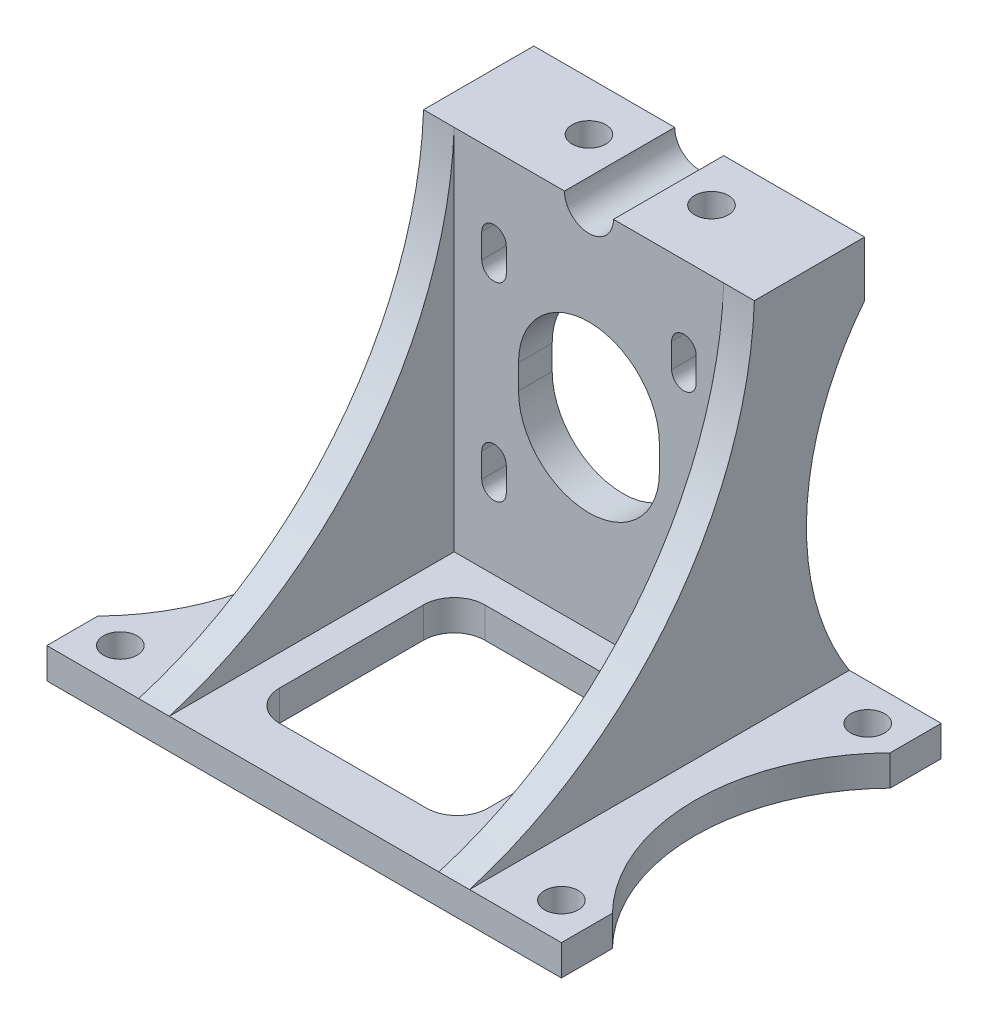
from build123d import *

# Parameters (mm, degrees)
BOSS_EXTRUDE1_DEPTH = 62
SKETCH2_W           = 10
SKETCH2_H           = 60
CUT_EXTRUDE1_DEPTH  = 85
SKETCH12_W          = 44
SKETCH12_H          = 51.120506265
CUT_EXTRUDE11_DEPTH = 30
SKETCH17_R          = 2.75
SKETCH17_R_2        = 32.5
CUT_EXTRUDE14_DEPTH = 6
CUT_EXTRUDE17_DEPTH = 10
CUT_EXTRUDE18_DEPTH = 6
SKETCH24_W          = 44
SKETCH24_H          = 8.565563784
CUT_EXTRUDE19_DEPTH = 31.0000001
BOSS_EXTRUDE2_DEPTH = 12.5
BOSS_EXTRUDE3_DEPTH = 5
CUT_EXTRUDE20_START = -0.6
CUT_EXTRUDE20_DEPTH = 3.4
SKETCH29_R          = 2.75
CUT_EXTRUDE21_DEPTH = 6
SKETCH33_R          = 2.75
BOSS_EXTRUDE5_DEPTH = 0.4


with BuildPart() as part:
    # Sketch1 → Boss-Extrude1 (new body)
    with BuildSketch(Plane.XY):
        with BuildLine():
            Line((-42, 0), (42, 0))
            Line((42, 0), (42, 5))
            Line((42, 5), (27, 5))
            Line((27, 5), (27, 65))
            Line((27, 65), (4, 65))
            ThreePointArc((4, 65), (0, 61), (-4, 65))
            Line((-4, 65), (-27, 65))
            Line((-27, 65), (-27, 5))
            Line((-27, 5), (-42, 5))
            Line((-42, 5), (-42, 0))
        make_face()
        with BuildLine():
            Line((-11.5, 37), (-11.5, 33))
            ThreePointArc((-11.5, 33), (0, 21.5), (11.5, 33))
            Line((11.5, 33), (11.5, 37))
            ThreePointArc((11.5, 37), (0, 48.5), (-11.5, 37))
        make_face(mode=Mode.SUBTRACT)
    extrude(amount=BOSS_EXTRUDE1_DEPTH)

    # Sketch2 → Cut-Extrude1 (cut, through all)
    with BuildSketch(Plane.ZY.offset(42)):
        with Locations((5, 35)):
            Rectangle(SKETCH2_W, SKETCH2_H)
        with BuildLine():
            Line((62, 5), (62, 65))
            Line((62, 65), (15.5, 65))
            ThreePointArc((15.5, 65), (29.081460906, 27.506882202), (62, 5))
        make_face()
    extrude(amount=-CUT_EXTRUDE1_DEPTH, mode=Mode.SUBTRACT)

    # Sketch12 → Cut-Extrude11 (cut)
    with BuildSketch(Plane(origin=(0, 5, 0), x_dir=(1, 0, 0), z_dir=(0, 1, 0))):
        with Locations((0, -41.060253133)):
            Rectangle(SKETCH12_W, SKETCH12_H)
    extrude(amount=CUT_EXTRUDE11_DEPTH, mode=Mode.SUBTRACT)

    # Sketch17 → Cut-Extrude14 (cut, through all)
    with BuildSketch(Plane(origin=(0, 5, 0), x_dir=(1, 0, 0), z_dir=(0, 1, 0))):
        with Locations(Location((-36, -6, 0), (0, 0, 180))):  # turned: the seam where the file's is
            Circle(SKETCH17_R)
        with Locations(Location((36, -6, 0), (0, 0, 180))):  # turned: the seam where the file's is
            Circle(SKETCH17_R)
        with Locations(Location((36, -56, 0), (0, 0, 180))):  # turned: the seam where the file's is
            Circle(SKETCH17_R)
        with Locations(Location((-36, -56, 0), (0, 0, 180))):  # turned: the seam where the file's is
            Circle(SKETCH17_R)
        with Locations((65.278831944, -31)):
            Circle(SKETCH17_R_2)
        with Locations((-65.278831944, -31)):
            Circle(SKETCH17_R_2)
    extrude(amount=-CUT_EXTRUDE14_DEPTH, mode=Mode.SUBTRACT)

    # Sketch20 → Cut-Extrude17 (cut)
    with BuildSketch(Plane.XY.offset(15.5)):
        with BuildLine():
            Line((-17.5, 52.5), (-17.5, 48.5))
            ThreePointArc((-17.5, 48.5), (-15.5, 46.5), (-13.5, 48.5))
            Line((-13.5, 48.5), (-13.5, 52.5))
            ThreePointArc((-13.5, 52.5), (-15.5, 54.5), (-17.5, 52.5))
        make_face()
        with BuildLine():
            Line((13.5, 52.5), (13.5, 48.5))
            ThreePointArc((13.5, 48.5), (15.5, 46.5), (17.5, 48.5))
            Line((17.5, 48.5), (17.5, 52.5))
            ThreePointArc((17.5, 52.5), (15.5, 54.5), (13.5, 52.5))
        make_face()
        with BuildLine():
            Line((-17.5, 21.5), (-17.5, 17.5))
            ThreePointArc((-17.5, 17.5), (-15.5, 15.5), (-13.5, 17.5))
            Line((-13.5, 17.5), (-13.5, 21.5))
            ThreePointArc((-13.5, 21.5), (-15.5, 23.5), (-17.5, 21.5))
        make_face()
        with BuildLine():
            Line((13.5, 17.5), (13.5, 21.5))
            ThreePointArc((13.5, 21.5), (15.5, 23.5), (17.5, 21.5))
            Line((17.5, 21.5), (17.5, 17.5))
            ThreePointArc((17.5, 17.5), (15.5, 15.5), (13.5, 17.5))
        make_face()
    extrude(amount=-CUT_EXTRUDE17_DEPTH, mode=Mode.SUBTRACT)

    # Sketch21 → Cut-Extrude18 (cut, through all)
    with BuildSketch(Plane(origin=(0, 5, 0), x_dir=(1, 0, 0), z_dir=(0, 1, 0))):
        with BuildLine():
            Line((-12, -20.5), (12, -20.5))
            ThreePointArc((12, -20.5), (15.535533906, -21.964466094), (17, -25.5))
            Line((17, -25.5), (17, -49))
            ThreePointArc((17, -49), (15.535533906, -52.535533906), (12, -54))
            Line((12, -54), (-12, -54))
            ThreePointArc((-12, -54), (-15.535533906, -52.535533906), (-17, -49))
            Line((-17, -49), (-17, -25.5))
            ThreePointArc((-17, -25.5), (-15.535533906, -21.964466094), (-12, -20.5))
        make_face()
    extrude(amount=-CUT_EXTRUDE18_DEPTH, mode=Mode.SUBTRACT)

    # Sketch24 → Cut-Extrude19 (cut, through all)
    with BuildSketch(Plane.XZ.offset(-35)):
        with Locations((0, 19.782781892)):
            Rectangle(SKETCH24_W, SKETCH24_H)
    extrude(amount=-CUT_EXTRUDE19_DEPTH, mode=Mode.SUBTRACT)

    # Sketch25 → Boss-Extrude2 (add)
    with BuildSketch(Plane(origin=(0, 0, 10), x_dir=(-1, 0, 0), z_dir=(0, 0, -1))):
        with BuildLine():
            Line((-27, 65), (-4, 65))
            ThreePointArc((-4, 65), (0, 61), (4, 65))
            Line((4, 65), (27, 65))
            Line((27, 65), (27, 56))
            Line((27, 56), (-27, 56))
            Line((-27, 56), (-27, 65))
        make_face()
    extrude(amount=BOSS_EXTRUDE2_DEPTH)

    # Sketch27 → Boss-Extrude3 (add)
    with BuildSketch(Plane.ZY.offset(27)):
        with BuildLine():
            Line((-2.5, 56), (10, 56))
            Line((10, 56), (10, 5))
            Line((10, 5), (0, 5))
            ThreePointArc((0, 5), (6.947455101, 30.901836034), (-2.5, 56))
        make_face()
    boss_extrude3 = extrude(amount=-BOSS_EXTRUDE3_DEPTH)

    # Mirror1: Boss-Extrude3 across plane
    add(boss_extrude3.mirror(Plane(origin=(0, 0, 0), x_dir=(0, 0, 1), z_dir=(1, 0, 0))))

    # Sketch28 → Cut-Extrude20 (cut)
    with BuildSketch(Plane.XZ.offset(-56).offset(CUT_EXTRUDE20_START)):
        Polygon((-5.092522712, 5.5), (-7.546261356, 9.75), (-12.453738644, 9.75), (-14.907477288, 5.5), (-12.453738644, 1.25), (-7.546261356, 1.25), align=None)
        Polygon((5.092522712, 5.5), (7.546261356, 1.25), (12.453738644, 1.25), (14.907477288, 5.5), (12.453738644, 9.75), (7.546261356, 9.75), align=None)
    extrude(amount=-CUT_EXTRUDE20_DEPTH, mode=Mode.SUBTRACT)

    # Sketch29 → Cut-Extrude21 (cut)
    with BuildSketch(Plane(origin=(0, 65, 0), x_dir=(1, 0, 0), z_dir=(0, 1, 0))):
        with Locations(Location((-10, -5.5, 0), (0, 0, 270))):  # turned: the seam where the file's is
            Circle(SKETCH29_R)
        with Locations(Location((10, -5.5, 0), (0, 0, 270))):  # turned: the seam where the file's is
            Circle(SKETCH29_R)
    extrude(amount=-CUT_EXTRUDE21_DEPTH, mode=Mode.SUBTRACT)

    # Sketch33 → Boss-Extrude5 (add)
    with BuildSketch(Plane.XZ.offset(-60)):
        with Locations(Location((10, 5.5, 0), (0, 0, 90))):  # turned: the seam where the file's is
            Circle(SKETCH33_R)
        with Locations(Location((-10, 5.5, 0), (0, 0, 90))):  # turned: the seam where the file's is
            Circle(SKETCH33_R)
    extrude(amount=-BOSS_EXTRUDE5_DEPTH)


solid = part.part
